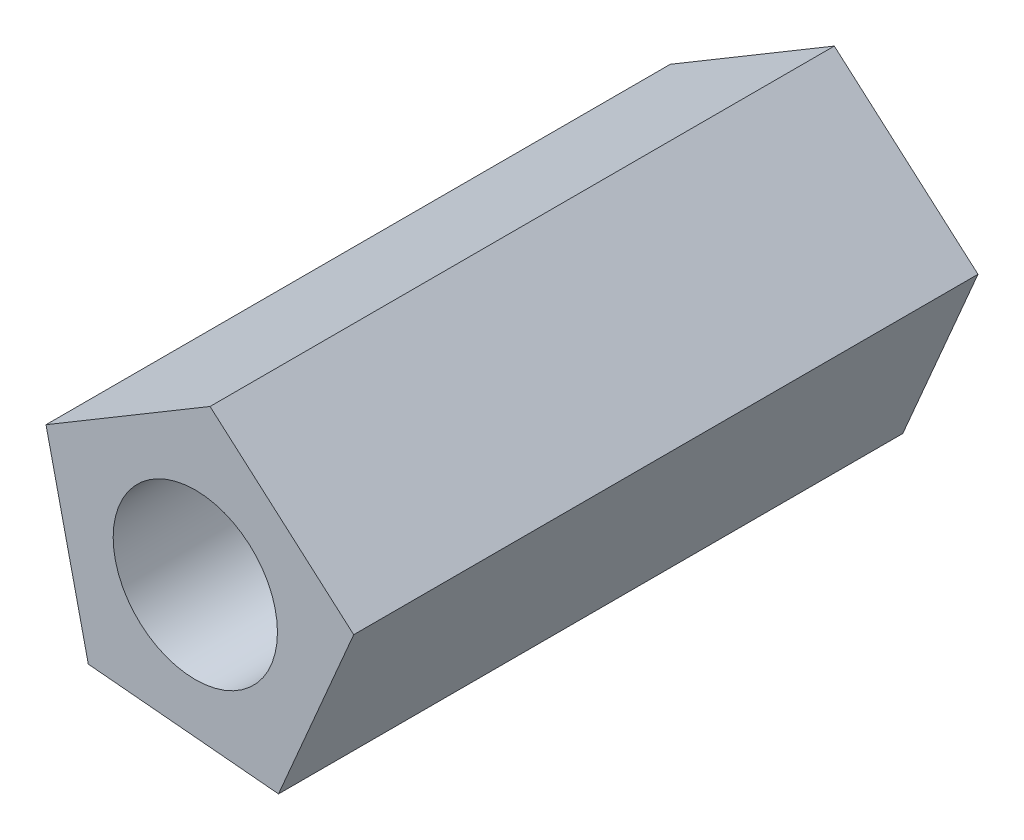
from build123d import *

# Parameters (mm, degrees)
IZIM1_R                     = 2.5
Y_KSEKLIK_EKSTR_ZYON1_DEPTH = 19


with BuildPart() as part:
    # Çizim1 → Yükseklik-Ekstrüzyon1 (new body)
    with BuildSketch(Plane.XY):
        Polygon((0.447956651, 4.923937404), (-4.544516536, 1.947612429), (-3.256622333, -3.720246726), (2.531813246, -4.246851352), (4.821368972, 1.095548245), align=None)
        Circle(IZIM1_R, mode=Mode.SUBTRACT)
    extrude(amount=Y_KSEKLIK_EKSTR_ZYON1_DEPTH)


solid = part.part
